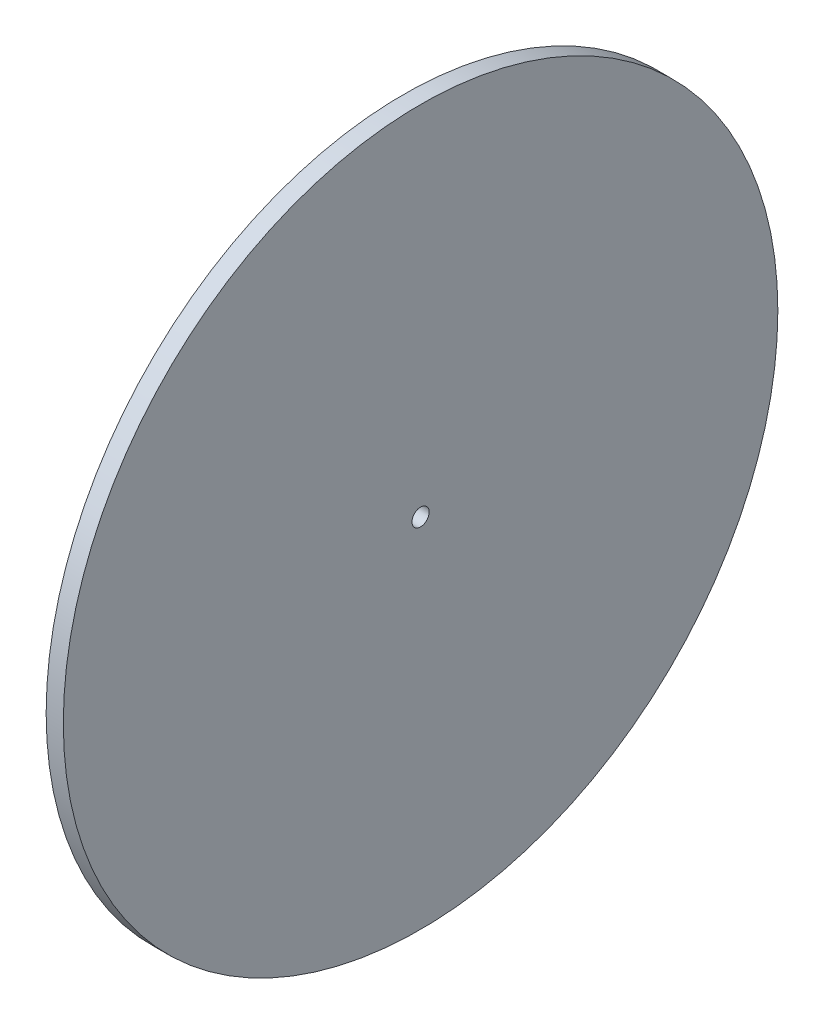
from build123d import *

# Parameters (mm, degrees)
SKETCH1_R           = 62.5
BOSS_EXTRUDE1_DEPTH = 3
SKETCH2_R           = 1.5
CUT_EXTRUDE1_DEPTH  = 4


with BuildPart() as part:
    # Sketch1 → Boss-Extrude1 (new body)
    with BuildSketch(Plane(origin=(0, 0, 0), x_dir=(0, 0, -1), z_dir=(1, 0, 0))):
        Circle(SKETCH1_R)
    extrude(amount=BOSS_EXTRUDE1_DEPTH)

    # Sketch2 → Cut-Extrude1 (cut, through all)
    with BuildSketch(Plane.ZY):
        Circle(SKETCH2_R)
    extrude(amount=-CUT_EXTRUDE1_DEPTH, mode=Mode.SUBTRACT)


solid = part.part
